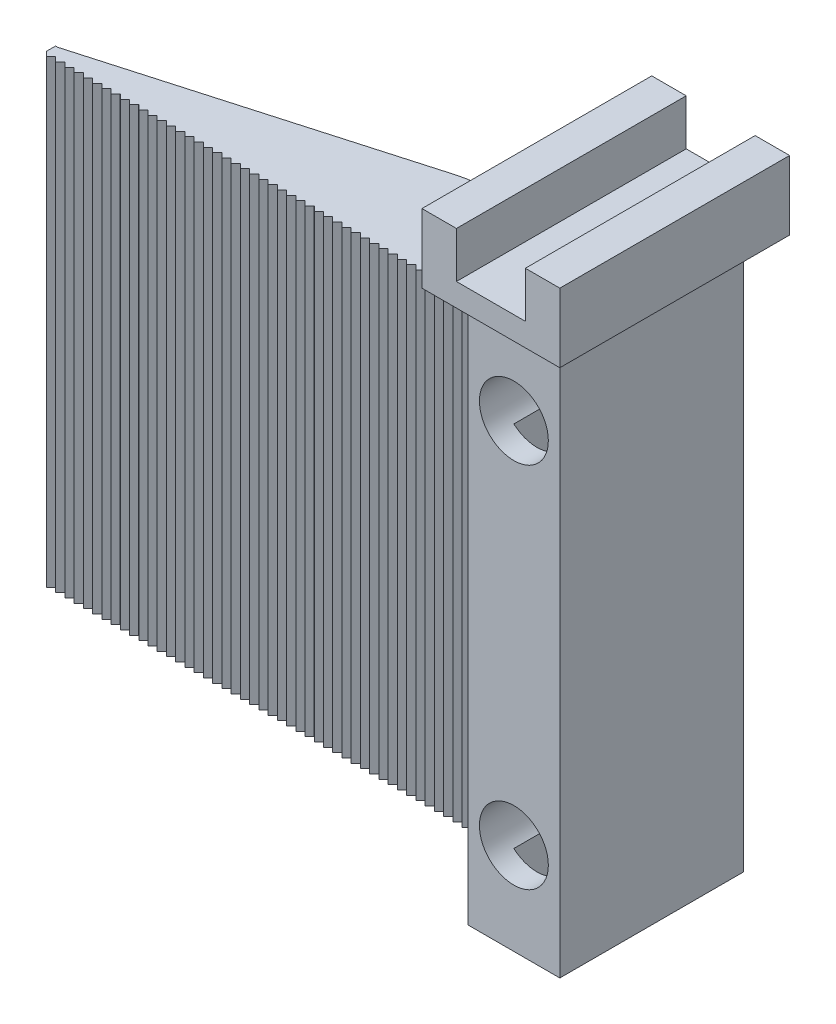
from build123d import *

# Parameters (mm, degrees)
BOSS_EXTRUDE1_DEPTH = 100
FILLET1_R           = 20
SKETCH5_W           = 40
SKETCH5_H           = 120
BOSS_EXTRUDE2_DEPTH = 20
SKETCH6_W           = 10
SKETCH6_H           = 30
CUT_EXTRUDE1_DEPTH  = 120
SKETCH7_W           = 100
SKETCH7_H           = 100
BOSS_EXTRUDE3_DEPTH = 2
BOSS_EXTRUDE4_DEPTH = 100
SKETCH11_W          = 0.49
SKETCH11_H          = 2
BOSS_EXTRUDE5_DEPTH = 100
SKETCH12_R          = 7.5
CUT_EXTRUDE2_DEPTH  = 40
SKETCH15_W          = 30
SKETCH15_H          = 50
BOSS_EXTRUDE6_DEPTH = 15
SKETCH16_W          = 15
SKETCH16_H          = 50
CUT_EXTRUDE3_DEPTH  = 10


with BuildPart() as part:
    # Sketch3 → Boss-Extrude1 (new body)
    with BuildSketch(Plane(origin=(0, 0, 0), x_dir=(1, 0, 0), z_dir=(0, 1, 0))):
        Polygon((0, 0), (100, 0), (100, 20), (70, 20), align=None)
    extrude(amount=BOSS_EXTRUDE1_DEPTH)

    # Fillet1
    fillet1_edges = [part.edges().sort_by_distance(p)[0] for p in [
        (70, 50, -20),
    ]]
    fillet(fillet1_edges, radius=FILLET1_R)

    # Sketch5 → Boss-Extrude2 (add)
    with BuildSketch(Plane(origin=(100, 0, 0), x_dir=(0, 0, -1), z_dir=(1, 0, 0))):
        with Locations((9.230478953, 50)):
            Rectangle(SKETCH5_W, SKETCH5_H)
    extrude(amount=BOSS_EXTRUDE2_DEPTH)

    # Sketch6 → Cut-Extrude1 (cut)
    with BuildSketch(Plane(origin=(0, 110, 0), x_dir=(1, 0, 0), z_dir=(0, 1, 0))):
        with Locations((110, 9.230478953)):
            Rectangle(SKETCH6_W, SKETCH6_H)
    extrude(amount=-CUT_EXTRUDE1_DEPTH, mode=Mode.SUBTRACT)

    # Sketch7 → Boss-Extrude3 (add)
    with BuildSketch(Plane.XY):
        with Locations((50, 50)):
            Rectangle(SKETCH7_W, SKETCH7_H)
    extrude(amount=BOSS_EXTRUDE3_DEPTH)

    # Sketch10 → Boss-Extrude4 (add)
    with BuildSketch(Plane(origin=(0, 100, 0), x_dir=(1, 0, 0), z_dir=(0, 1, 0))):
        Polygon((100, -2), (98, -2), (99, -3), align=None)
        Polygon((95.99, -2), (96.99, -3), (97.99, -2), align=None)
        Polygon((93.98, -2), (94.98, -3), (95.98, -2), align=None)
        Polygon((91.97, -2), (92.97, -3), (93.97, -2), align=None)
        Polygon((89.96, -2), (90.96, -3), (91.96, -2), align=None)
        Polygon((87.95, -2), (88.95, -3), (89.95, -2), align=None)
        Polygon((85.94, -2), (86.94, -3), (87.94, -2), align=None)
        Polygon((83.93, -2), (84.93, -3), (85.93, -2), align=None)
        Polygon((81.92, -2), (82.92, -3), (83.92, -2), align=None)
        Polygon((79.91, -2), (80.91, -3), (81.91, -2), align=None)
        Polygon((77.9, -2), (78.9, -3), (79.9, -2), align=None)
        Polygon((75.89, -2), (76.89, -3), (77.89, -2), align=None)
        Polygon((73.88, -2), (74.88, -3), (75.88, -2), align=None)
        Polygon((71.87, -2), (72.87, -3), (73.87, -2), align=None)
        Polygon((69.86, -2), (70.86, -3), (71.86, -2), align=None)
        Polygon((67.85, -2), (68.85, -3), (69.85, -2), align=None)
        Polygon((65.84, -2), (66.84, -3), (67.84, -2), align=None)
        Polygon((63.83, -2), (64.83, -3), (65.83, -2), align=None)
        Polygon((61.82, -2), (62.82, -3), (63.82, -2), align=None)
        Polygon((59.81, -2), (60.81, -3), (61.81, -2), align=None)
        Polygon((57.8, -2), (58.8, -3), (59.8, -2), align=None)
        Polygon((55.79, -2), (56.79, -3), (57.79, -2), align=None)
        Polygon((53.78, -2), (54.78, -3), (55.78, -2), align=None)
        Polygon((51.77, -2), (52.77, -3), (53.77, -2), align=None)
        Polygon((49.76, -2), (50.76, -3), (51.76, -2), align=None)
        Polygon((47.75, -2), (48.75, -3), (49.75, -2), align=None)
        Polygon((45.74, -2), (46.74, -3), (47.74, -2), align=None)
        Polygon((43.73, -2), (44.73, -3), (45.73, -2), align=None)
        Polygon((41.72, -2), (42.72, -3), (43.72, -2), align=None)
        Polygon((39.71, -2), (40.71, -3), (41.71, -2), align=None)
        Polygon((37.7, -2), (38.7, -3), (39.7, -2), align=None)
        Polygon((35.69, -2), (36.69, -3), (37.69, -2), align=None)
        Polygon((33.68, -2), (34.68, -3), (35.68, -2), align=None)
        Polygon((31.67, -2), (32.67, -3), (33.67, -2), align=None)
        Polygon((29.66, -2), (30.66, -3), (31.66, -2), align=None)
        Polygon((27.65, -2), (28.65, -3), (29.65, -2), align=None)
        Polygon((25.64, -2), (26.64, -3), (27.64, -2), align=None)
        Polygon((23.63, -2), (24.63, -3), (25.63, -2), align=None)
        Polygon((21.62, -2), (22.62, -3), (23.62, -2), align=None)
        Polygon((19.61, -2), (20.61, -3), (21.61, -2), align=None)
        Polygon((17.6, -2), (18.6, -3), (19.6, -2), align=None)
        Polygon((15.59, -2), (16.59, -3), (17.59, -2), align=None)
        Polygon((13.58, -2), (14.58, -3), (15.58, -2), align=None)
        Polygon((11.57, -2), (12.57, -3), (13.57, -2), align=None)
        Polygon((9.56, -2), (10.56, -3), (11.56, -2), align=None)
        Polygon((7.55, -2), (8.55, -3), (9.55, -2), align=None)
        Polygon((5.54, -2), (6.54, -3), (7.54, -2), align=None)
        Polygon((3.53, -2), (4.53, -3), (5.53, -2), align=None)
        Polygon((1.52, -2), (2.52, -3), (3.52, -2), align=None)
        Polygon((-0.49, -2), (0.51, -3), (1.51, -2), align=None)
    extrude(amount=-BOSS_EXTRUDE4_DEPTH)

    # Sketch11 → Boss-Extrude5 (add)
    with BuildSketch(Plane(origin=(0, 100, 0), x_dir=(1, 0, 0), z_dir=(0, 1, 0))):
        with Locations((-0.245, -1)):
            Rectangle(SKETCH11_W, SKETCH11_H)
    extrude(amount=-BOSS_EXTRUDE5_DEPTH)

    # Sketch12 → Cut-Extrude2 (cut)
    with BuildSketch(Plane.XY.offset(10.769521047)):
        with Locations((110, 10)):
            Circle(SKETCH12_R)
        with Locations((110, 90)):
            Circle(SKETCH12_R)
    extrude(amount=-CUT_EXTRUDE2_DEPTH, mode=Mode.SUBTRACT)

    # Sketch15 → Boss-Extrude6 (add)
    with BuildSketch(Plane(origin=(0, 110, 0), x_dir=(1, 0, 0), z_dir=(0, 1, 0))):
        with Locations((110, 9.230478953)):
            Rectangle(SKETCH15_W, SKETCH15_H)
    extrude(amount=BOSS_EXTRUDE6_DEPTH)

    # Sketch16 → Cut-Extrude3 (cut)
    with BuildSketch(Plane(origin=(0, 125, 0), x_dir=(1, 0, 0), z_dir=(0, 1, 0))):
        with Locations((110, 9.230478953)):
            Rectangle(SKETCH16_W, SKETCH16_H)
    extrude(amount=-CUT_EXTRUDE3_DEPTH, mode=Mode.SUBTRACT)


solid = part.part
